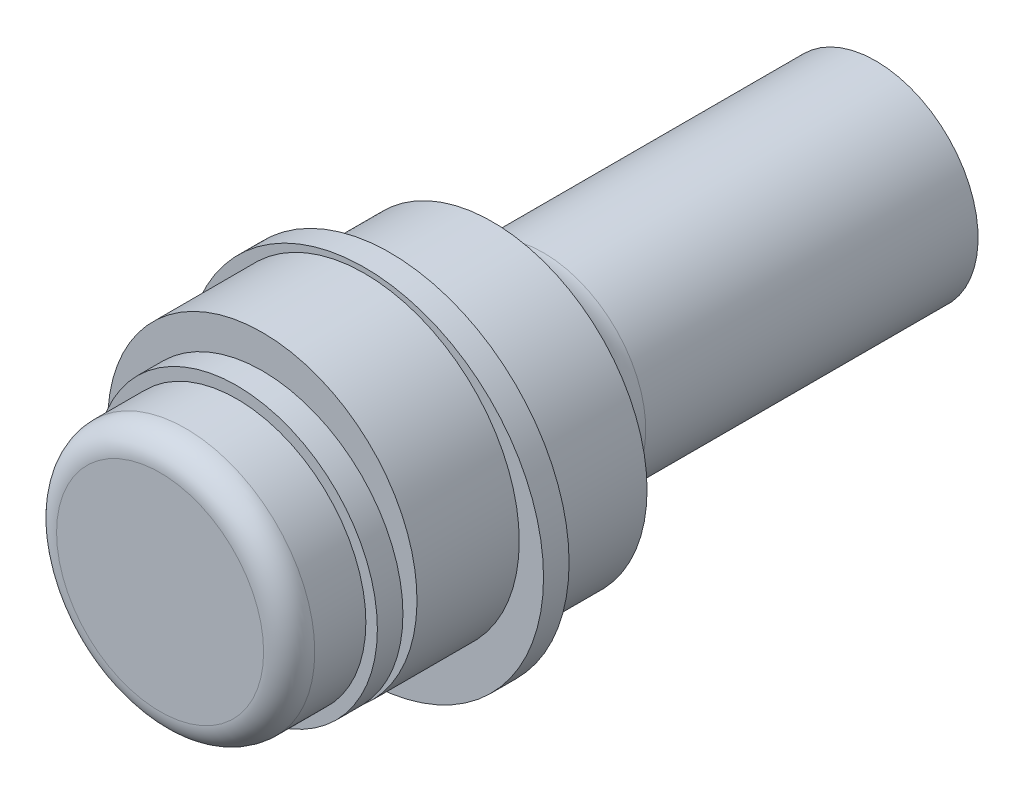
from build123d import *

# Parameters (mm, degrees)
SKETCH_1_R      = 6.05
EXTRUDE_1_DEPTH = 5
SKETCH_7_R      = 7
EXTRUDE_6_DEPTH = 1
SKETCH_2_R      = 6.05
EXTRUDE_2_DEPTH = 4
EXTRUDE_3_DEPTH = 15
FILLET_1_R      = 2
SKETCH_5_R      = 5.5
EXTRUDE_4_DEPTH = 1
SKETCH_6_R      = 5.05
EXTRUDE_5_DEPTH = 3
FILLET_2_R      = 1


with BuildPart() as part:
    # 草图1 → 凸台-拉伸1 (new body)
    with BuildSketch(Plane.XY):
        Circle(SKETCH_1_R)
    extrude(amount=EXTRUDE_1_DEPTH)

    # 草图7 → 凸台-拉伸6 (add)
    with BuildSketch(Plane.XY.offset(5)):
        Circle(SKETCH_7_R)
    extrude(amount=-EXTRUDE_6_DEPTH)

    # 草图2 → 凸台-拉伸2 (add)
    with BuildSketch(Plane.XY.offset(5)):
        with Locations((0, 0.75)):
            Circle(SKETCH_2_R)
    extrude(amount=EXTRUDE_2_DEPTH)

    # 草图4 → 凸台-拉伸3 (add)
    with BuildSketch(Plane(origin=(0, 0, 0), x_dir=(-1, 0, 0), z_dir=(0, 0, -1))):
        with BuildLine():
            ThreePointArc((4, 0), (-1.645751311, 3.645751311), (-2.645751311, -3))
            Line((-2.645751311, -3), (2.645751311, -3))
            ThreePointArc((2.645751311, -3), (3.645751311, -1.645751311), (4, 0))
        make_face()
    extrude(amount=EXTRUDE_3_DEPTH)

    # 圆角1
    fillet_1_edges = [part.edges().sort_by_distance(p)[0] for p in [
        (0, -3, 0),
        (0, 4, 0),
    ]]
    fillet(fillet_1_edges, radius=FILLET_1_R)

    # 草图5 → 凸台-拉伸4 (add)
    with BuildSketch(Plane.XY.offset(9)):
        Circle(SKETCH_5_R)
    extrude(amount=EXTRUDE_4_DEPTH)

    # 草图6 → 凸台-拉伸5 (add)
    with BuildSketch(Plane.XY.offset(10)):
        Circle(SKETCH_6_R)
    extrude(amount=EXTRUDE_5_DEPTH)

    # 圆角2
    fillet_2_edges = [part.edges().sort_by_distance(p)[0] for p in [
        (-5.05, 0, 13),
    ]]
    fillet(fillet_2_edges, radius=FILLET_2_R)


solid = part.part
